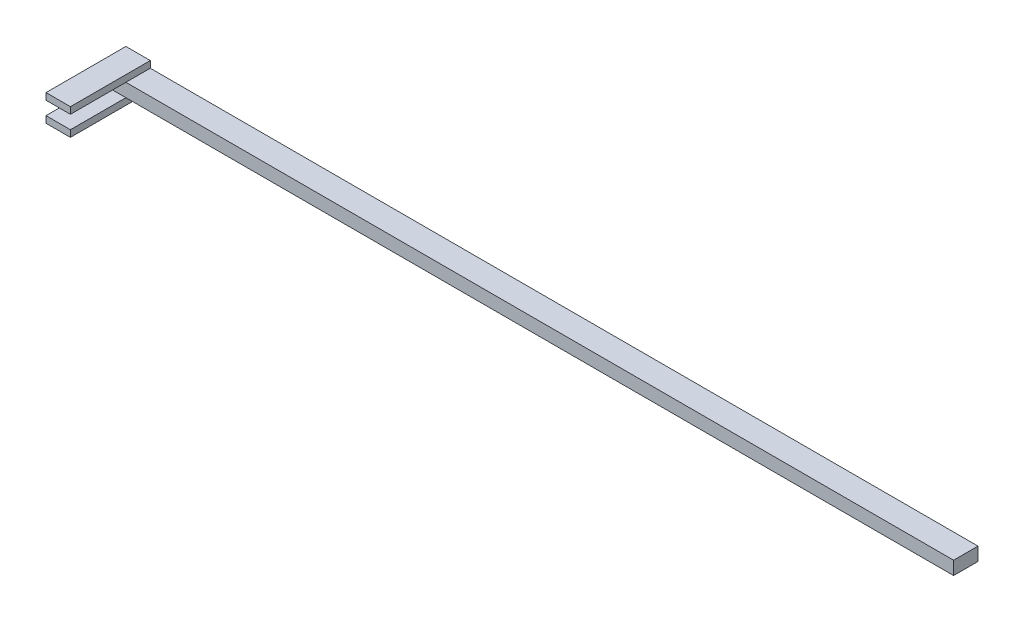
from build123d import *

# Parameters (mm, degrees)
SKETCH1_W           = 4876.8
SKETCH1_H           = 139.7
BOSS_EXTRUDE1_DEPTH = 38.1
SKETCH2_W           = 139.7
SKETCH2_H           = 457.2
BOSS_EXTRUDE2_DEPTH = 38.1


with BuildPart() as part:
    # Sketch1 → Boss-Extrude1 (new body)
    with BuildSketch(Plane(origin=(0, 0, 0), x_dir=(1, 0, 0), z_dir=(0, 1, 0))):
        with Locations((2374.302612985, 77.362661321)):
            Rectangle(SKETCH1_W, SKETCH1_H)
    boss_extrude1 = extrude(amount=BOSS_EXTRUDE1_DEPTH)

    # Sketch2 → Boss-Extrude2 (add)
    with BuildSketch(Plane(origin=(0, 38.1, 0), x_dir=(1, 0, 0), z_dir=(0, 1, 0))):
        with Locations((5.752612985, -81.387338679)):
            Rectangle(SKETCH2_W, SKETCH2_H)
    boss_extrude2 = extrude(amount=BOSS_EXTRUDE2_DEPTH)

    # Mirror1: Boss-Extrude1, Boss-Extrude2 across plane
    add(boss_extrude1.mirror(Plane(origin=(-64.097387015, 0, -7.512661321), x_dir=(0, 0, 1), z_dir=(0, 1, 0))))
    add(boss_extrude2.mirror(Plane(origin=(-64.097387015, 0, -7.512661321), x_dir=(0, 0, 1), z_dir=(0, 1, 0))))


solid = part.part
